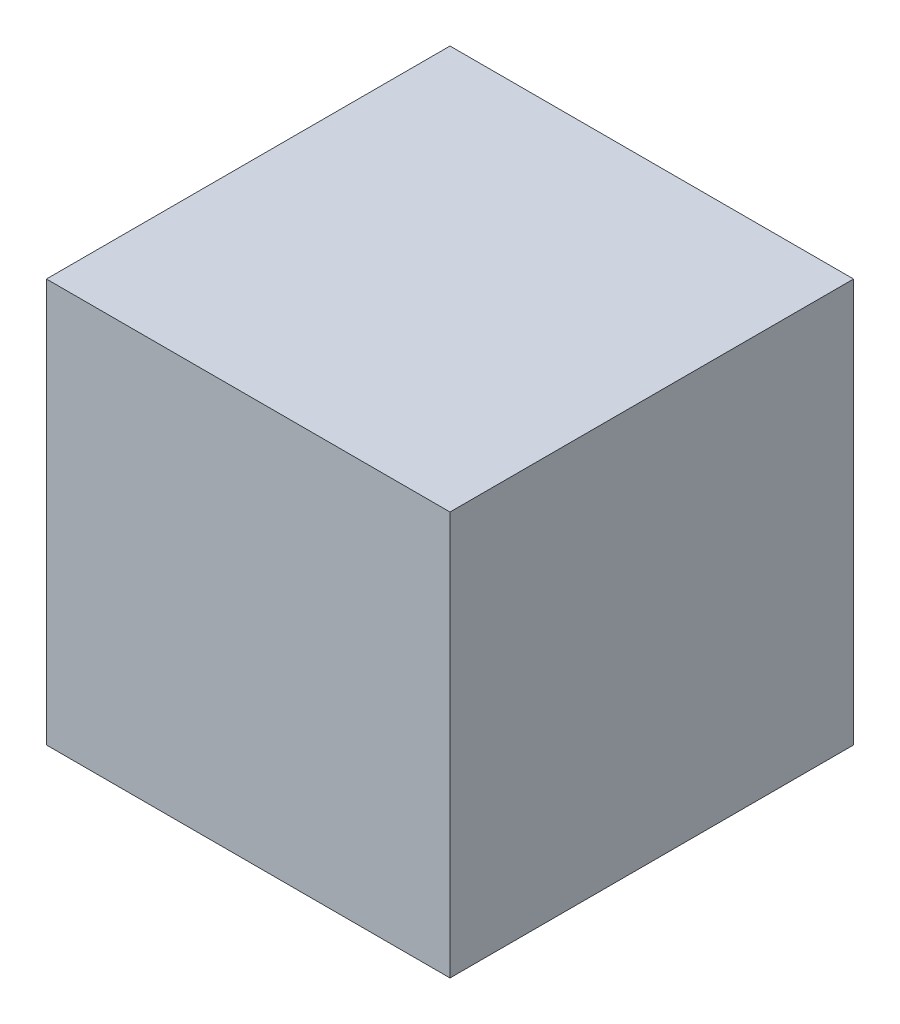
from build123d import *

# Parameters (mm, degrees)
CROQUIS1_W              = 30
CROQUIS1_H              = 30
SALIENTE_EXTRUIR1_DEPTH = 30


with BuildPart() as part:
    # Croquis1 → Saliente-Extruir1 (new body)
    with BuildSketch(Plane(origin=(0, 0, 0), x_dir=(1, 0, 0), z_dir=(0, 1, 0))):
        Rectangle(CROQUIS1_W, CROQUIS1_H)
    extrude(amount=SALIENTE_EXTRUIR1_DEPTH)


solid = part.part
